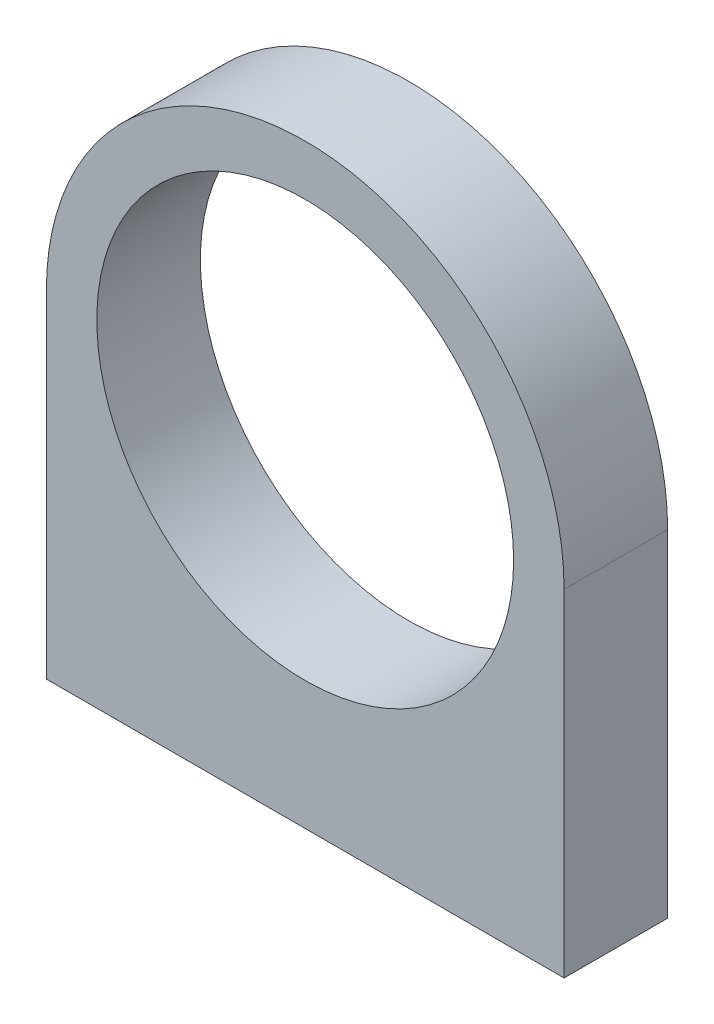
from build123d import *

# Parameters (mm, degrees)
ESQUISSE1_R             = 16.1
BOSS_EXTRU_1_DEPTH      = 8
ESQUISSE2_R             = 1.25
ENL_V_MAT_EXTRU_1_DEPTH = 15


with BuildPart() as part:
    # Esquisse1 → Boss.-Extru.1 (new body)
    with BuildSketch(Plane.XY):
        with BuildLine():
            Line((-20, 0), (-20, -26))
            Line((-20, -26), (20, -26))
            Line((20, -26), (20, 0))
            ThreePointArc((20, 0), (0, 20), (-20, 0))
        make_face()
        Circle(ESQUISSE1_R, mode=Mode.SUBTRACT)
    extrude(amount=BOSS_EXTRU_1_DEPTH)

    # Esquisse2 → Enlèv. mat.-Extru.1 (cut)
    with BuildSketch(Plane.XZ.offset(26)):
        with Locations((-16, 4)):
            Circle(ESQUISSE2_R)
        with Locations((16, 4)):
            Circle(ESQUISSE2_R)
    extrude(amount=-ENL_V_MAT_EXTRU_1_DEPTH, mode=Mode.SUBTRACT)


solid = part.part
